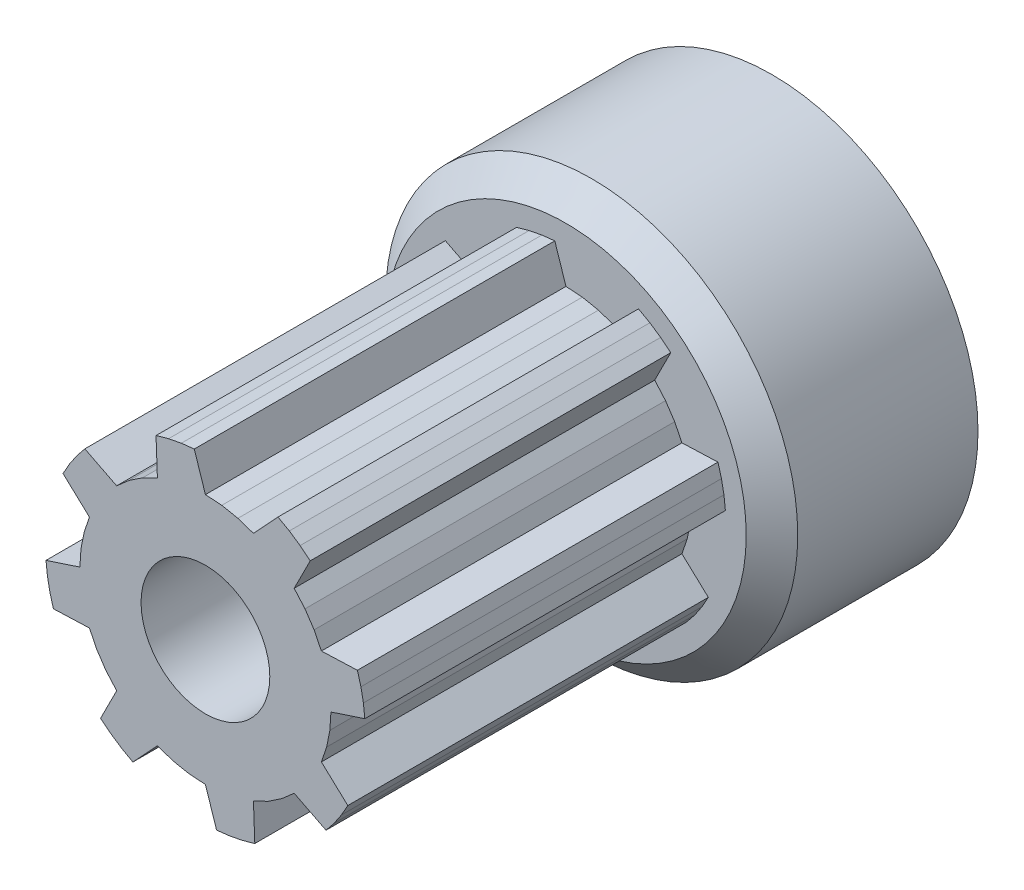
from build123d import *

# Parameters (mm, degrees)
SKETCH2_R           = 2.5
BOSS_EXTRUDE1_DEPTH = 14
SKETCH3_R           = 8
BOSS_EXTRUDE2_DEPTH = 8
SKETCH4_R           = 2.5
CUT_EXTRUDE1_DEPTH  = 23
CHAMFER1_SIZE       = 1


with BuildPart() as part:
    # Sketch2 → Boss-Extrude1 (new body)
    with BuildSketch(Plane.XY):
        Polygon((4.873707771, 0), (4.832012177, -0.636146486), (4.707640171, -1.261407971), (4.502718925, -1.865087032), (5.52904892, -2.817190886), (5.281517029, -3.257688046), (4.998967171, -3.676585913), (4.683272839, -4.071106911), (3.44623208, -3.44623208), (2.966924906, -3.866571903), (2.436853886, -4.2207551), (1.865087032, -4.502718925), (1.917572975, -5.901682854), (1.431063056, -6.038129807), (0.935064673, -6.134541988), (0.432866603, -6.190280914), (0, -4.873707771), (-0.636146486, -4.832012177), (-1.261407971, -4.707640171), (-1.865087032, -4.502718925), (-2.817190886, -5.52904892), (-3.257688046, -5.281517029), (-3.676585913, -4.998967171), (-4.071106911, -4.683272839), (-3.44623208, -3.44623208), (-3.866571903, -2.966924906), (-4.2207551, -2.436853886), (-4.502718925, -1.865087032), (-5.901682854, -1.917572975), (-6.038129807, -1.431063056), (-6.134541988, -0.935064673), (-6.190280914, -0.432866603), (-4.873707771, 0), (-4.832012177, 0.636146486), (-4.707640171, 1.261407971), (-4.502718925, 1.865087032), (-5.52904892, 2.817190886), (-5.281517029, 3.257688046), (-4.998967171, 3.676585913), (-4.683272839, 4.071106911), (-3.44623208, 3.44623208), (-2.966924906, 3.866571903), (-2.436853886, 4.2207551), (-1.865087032, 4.502718925), (-1.917572975, 5.901682854), (-1.431063056, 6.038129807), (-0.935064673, 6.134541988), (-0.432866603, 6.190280914), (0, 4.873707771), (0.636146486, 4.832012177), (1.261407971, 4.707640171), (1.865087032, 4.502718925), (2.817190886, 5.52904892), (3.257688046, 5.281517029), (3.676585913, 4.998967171), (4.071106911, 4.683272839), (3.44623208, 3.44623208), (3.866571903, 2.966924906), (4.2207551, 2.436853886), (4.502718925, 1.865087032), (5.901682854, 1.917572975), (6.038129807, 1.431063056), (6.134541988, 0.935064673), (6.190280914, 0.432866603), align=None)
        Circle(SKETCH2_R, mode=Mode.SUBTRACT)
    extrude(amount=BOSS_EXTRUDE1_DEPTH)

    # Sketch3 → Boss-Extrude2 (add)
    with BuildSketch(Plane(origin=(0, 0, 0), x_dir=(-1, 0, 0), z_dir=(0, 0, -1))):
        Circle(SKETCH3_R)
    extrude(amount=BOSS_EXTRUDE2_DEPTH)

    # Sketch4 → Cut-Extrude1 (cut, through all)
    with BuildSketch(Plane(origin=(0, 0, -8), x_dir=(-1, 0, 0), z_dir=(0, 0, -1))):
        Circle(SKETCH4_R)
    extrude(amount=-CUT_EXTRUDE1_DEPTH, mode=Mode.SUBTRACT)

    # Chamfer1
    chamfer1_edges = [part.edges().sort_by_distance(p)[0] for p in [
        (8, 0, 0),
    ]]
    chamfer(chamfer1_edges, length=CHAMFER1_SIZE)


solid = part.part
